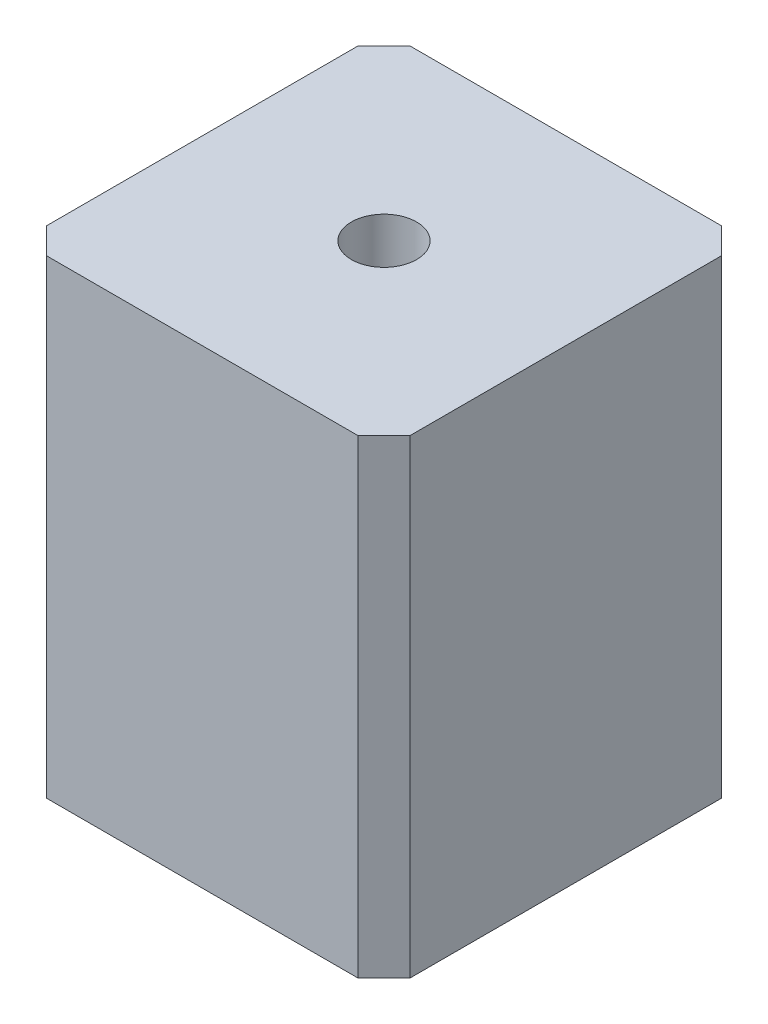
from build123d import *

# Parameters (mm, degrees)
SKETCH_2_W      = 27.85
SKETCH_2_H      = 27.85
SKETCH_2_R      = 2.5
EXTRUDE_1_DEPTH = 36
CHAMFER_1_SIZE  = 2


with BuildPart() as part:
    # Эскиз2 → Бобышка-Вытянуть1 (new body)
    with BuildSketch(Plane(origin=(0, 0, 0), x_dir=(1, 0, 0), z_dir=(0, 1, 0))):
        Rectangle(SKETCH_2_W, SKETCH_2_H)
        Circle(SKETCH_2_R, mode=Mode.SUBTRACT)
    extrude(amount=EXTRUDE_1_DEPTH)

    # Фаска1
    chamfer_1_edges = [part.edges().sort_by_distance(p)[0] for p in [
        (13.925, 18, -13.925),
        (13.925, 18, 13.925),
        (-13.925, 18, 13.925),
        (-13.925, 18, -13.925),
    ]]
    chamfer(chamfer_1_edges, length=CHAMFER_1_SIZE)


solid = part.part
